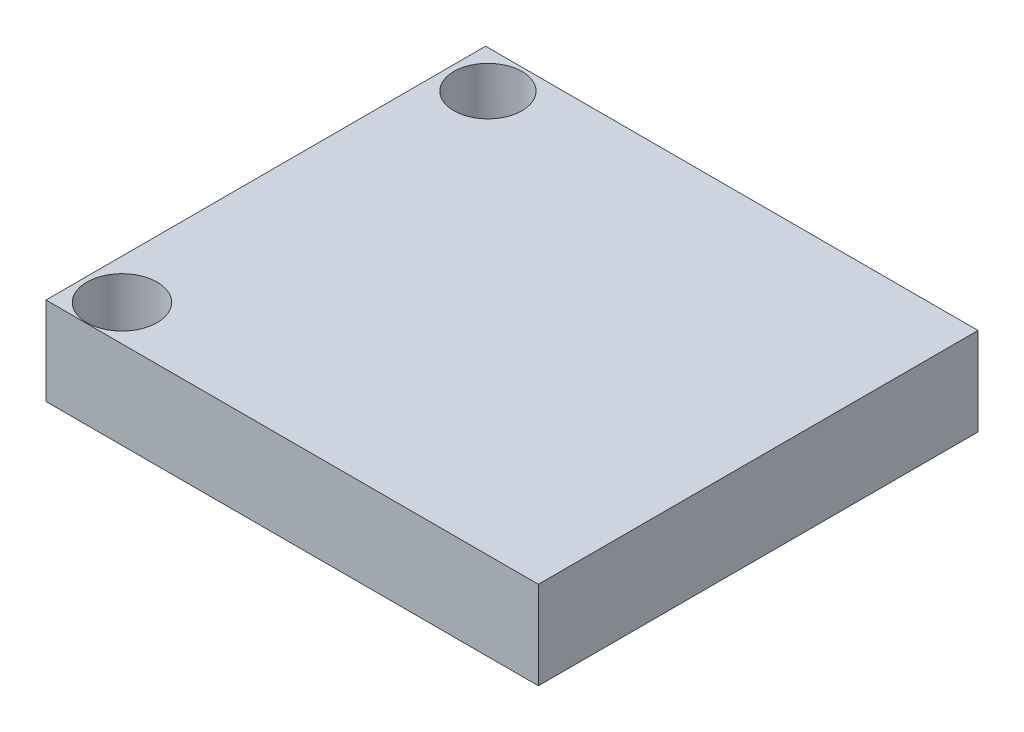
from build123d import *

# Parameters (mm, degrees)
SKETCH1_W           = 28
SKETCH1_H           = 25
BOSS_EXTRUDE1_DEPTH = 5
SKETCH2_R           = 1.936939751
SKETCH2_R_2         = 2
CUT_EXTRUDE1_DEPTH  = 10


with BuildPart() as part:
    # Sketch1 → Boss-Extrude1 (new body)
    with BuildSketch(Plane(origin=(0, 0, 0), x_dir=(1, 0, 0), z_dir=(0, 1, 0))):
        Rectangle(SKETCH1_W, SKETCH1_H)
    extrude(amount=BOSS_EXTRUDE1_DEPTH)

    # Sketch2 → Cut-Extrude1 (cut)
    with BuildSketch(Plane(origin=(0, 5, 0), x_dir=(1, 0, 0), z_dir=(0, 1, 0))):
        with Locations((-11.723724934, 10.3532906)):
            Circle(SKETCH2_R)
        with Locations((-11.723724934, -10.456411058)):
            Circle(SKETCH2_R_2)
    extrude(amount=-CUT_EXTRUDE1_DEPTH, mode=Mode.SUBTRACT)


solid = part.part
